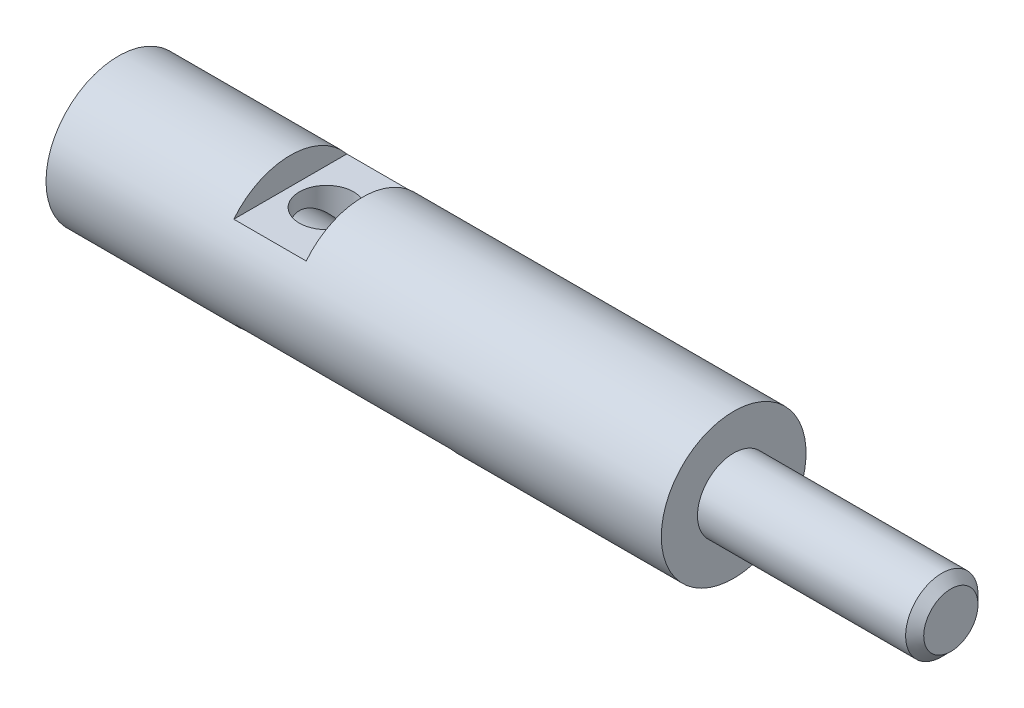
from build123d import *

# Parameters (mm, degrees)
SKETCH_3_W                  = 12
SKETCH_3_H                  = 3.426661337
SKETCH_3_W_2                = 4
SKETCH_3_H_2                = 2.458257046
CUT_EXTRUDE_1_DEPTH         = 5
CUT_EXTRUDE_1_DEPTH_BACK    = 5
HOLE_WIZARD_3_2_3_2_1_D     = 3.2
HOLE_WIZARD_3_2_3_2_1_DEPTH = 14
HOLE_WIZARD_3_2_3_2_1_TIP   = 0.96137699
CUT_EXTRUDE_2_REACH         = 8.5
SKETCH_6_R                  = 1.5


with BuildPart() as part:
    # Эскиз1 → Повернуть1 (revolve)
    with BuildSketch(Plane.XY):
        Polygon((0, 0), (0, 4), (34, 4), (34, 2), (45.5, 2), (46, 1.5), (46, 0), align=None)
    revolve(axis=Axis((0, 0, 0), (1, 0, 0)))

    # Эскиз3 → Вырез-Вытянуть1 (cut, two sides)
    with BuildSketch(Plane.XY) as cut_extrude_1_sk:
        with Locations((15.5, -4.213330669)):
            Rectangle(SKETCH_3_W, SKETCH_3_H)
        with Locations((11.5, 3.729128523)):
            Rectangle(SKETCH_3_W_2, SKETCH_3_H_2)
    extrude(amount=CUT_EXTRUDE_1_DEPTH, mode=Mode.SUBTRACT)
    extrude(cut_extrude_1_sk.sketch, amount=-CUT_EXTRUDE_1_DEPTH_BACK, mode=Mode.SUBTRACT)

    # Диаметр отверстия Ø3.2 (3.2)1
    with Locations(Plane.ZY):
        with Locations((0, 0)):
            Hole(HOLE_WIZARD_3_2_3_2_1_D / 2, depth=HOLE_WIZARD_3_2_3_2_1_DEPTH)
            with Locations((0, 0, -(HOLE_WIZARD_3_2_3_2_1_DEPTH + HOLE_WIZARD_3_2_3_2_1_TIP / 2))):  # 118° drill point
                Cone(0, HOLE_WIZARD_3_2_3_2_1_D / 2, HOLE_WIZARD_3_2_3_2_1_TIP, mode=Mode.SUBTRACT)

    # Эскиз6 → Вырез-Вытянуть2 (cut, up to next)
    with BuildSketch(Plane(origin=(0, 2.5, 0), x_dir=(1, 0, 0), z_dir=(0, 1, 0)), mode=Mode.PRIVATE) as cut_extrude_2_sk1:
        with Locations((11.5, 0)):
            Circle(SKETCH_6_R)
    cut_extrude_2_tool1 = extrude(cut_extrude_2_sk1.sketch, amount=-CUT_EXTRUDE_2_REACH, mode=Mode.PRIVATE) & part.part
    add(cut_extrude_2_tool1.solids().sort_by_distance((11.5, 2.5, 0))[0], mode=Mode.SUBTRACT)


solid = part.part
